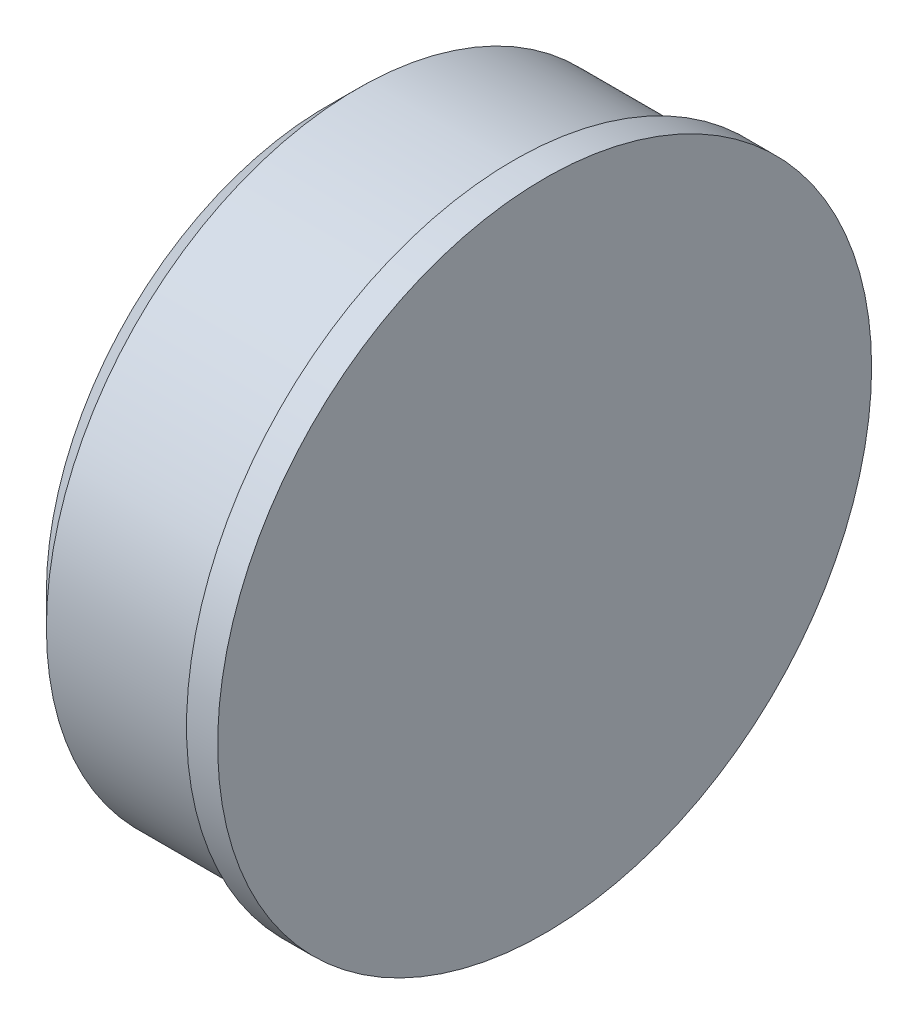
from build123d import *

# Parameters (mm, degrees)
ESQUISSE1_R      = 10.5
EXTRUSION1_DEPTH = 1
ESQUISSE2_R      = 10
ESQUISSE2_R_2    = 7.75
EXTRUSION2_DEPTH = 6
CHANFREIN1_SIZE  = 1


with BuildPart() as part:
    # Esquisse1 → Extrusion1 (new body)
    with BuildSketch(Plane(origin=(0, 0, 0), x_dir=(0, 0, -1), z_dir=(1, 0, 0))):
        Circle(ESQUISSE1_R)
    extrude(amount=EXTRUSION1_DEPTH)

    # Esquisse2 → Extrusion2 (add)
    with BuildSketch(Plane.ZY):
        with Locations(Location((0, 0, 0), (0, 0, 180))):  # turned: the seam where the file's is
            Circle(ESQUISSE2_R)
        Circle(ESQUISSE2_R_2, mode=Mode.SUBTRACT)
    extrude(amount=EXTRUSION2_DEPTH)

    # Chanfrein1
    chanfrein1_edges = [part.edges().sort_by_distance(p)[0] for p in [
        (-6, 0, 10),
    ]]
    chamfer(chanfrein1_edges, length=CHANFREIN1_SIZE)


solid = part.part
